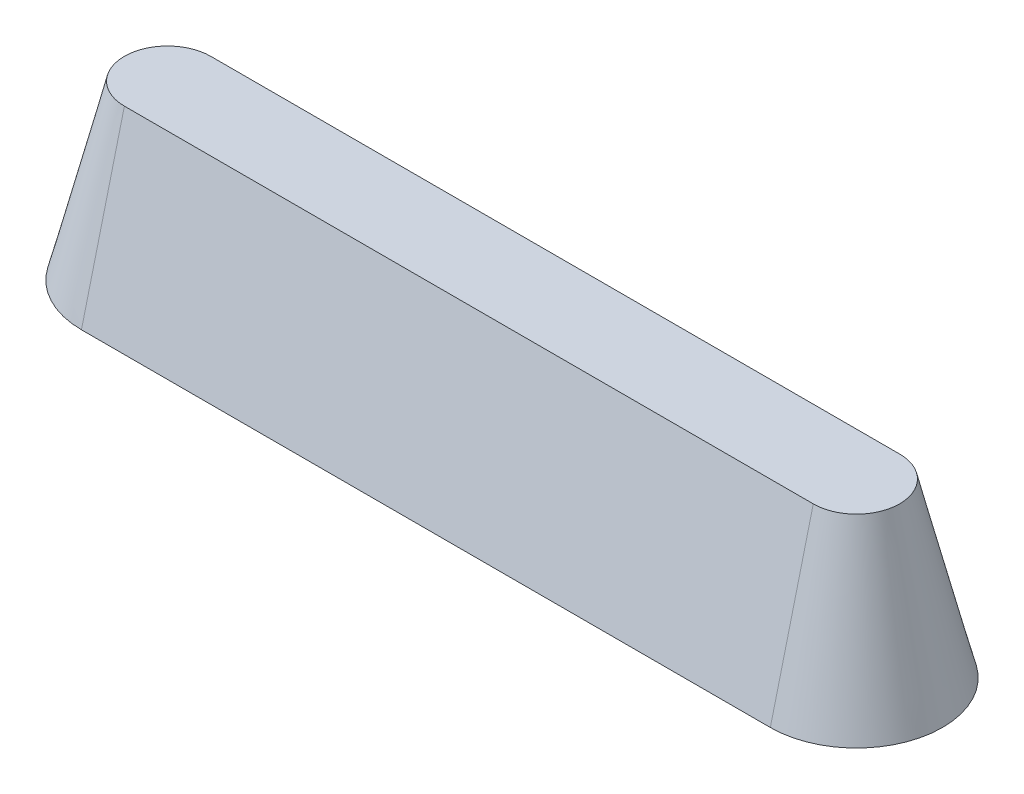
from build123d import *

# Parameters (mm, degrees)
SALIENTE_EXTRUIR1_DEPTH = 30
SALIENTE_EXTRUIR1_TAPER = 14


with BuildPart() as part:
    # Croquis1 → Saliente-Extruir1 (new body)
    with BuildSketch(Plane(origin=(0, 0, 0), x_dir=(1, 0, 0), z_dir=(0, 1, 0))):
        with BuildLine():
            ThreePointArc((-157.142857143, 15), (-172.142857143, 0), (-157.142857143, -15))
            Line((-157.142857143, -15), (-37.142857143, -15))
            ThreePointArc((-37.142857143, -15), (-22.142857143, 0), (-37.142857143, 15))
            Line((-37.142857143, 15), (-157.142857143, 15))
        make_face()
    extrude(amount=SALIENTE_EXTRUIR1_DEPTH, taper=SALIENTE_EXTRUIR1_TAPER)


solid = part.part
